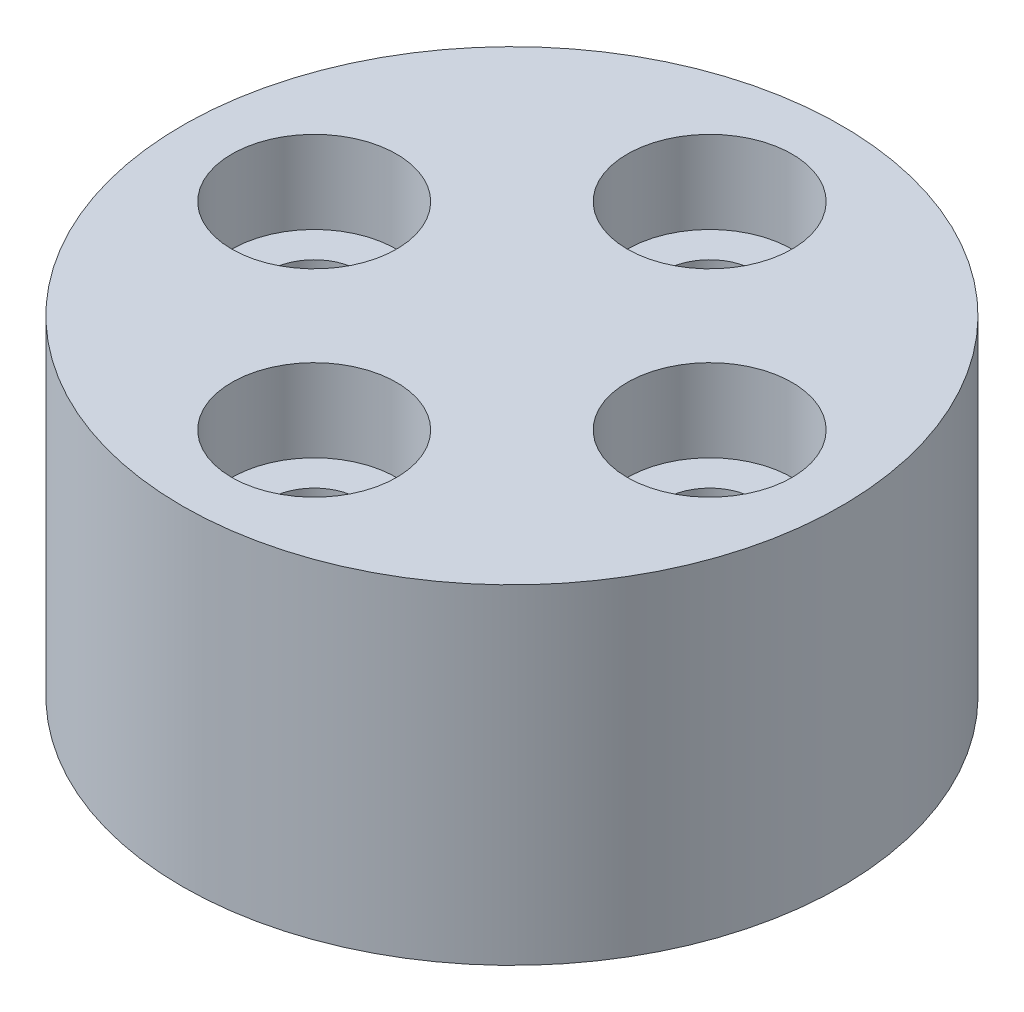
from build123d import *

# Parameters (mm, degrees)
SKETCH1_R                               = 20
BOSS_EXTRUDE1_DEPTH                     = 20
CBORE_FOR_M5_HEX_HEAD_BOLT5_D           = 5.5
CBORE_FOR_M5_HEX_HEAD_BOLT5_CBORE_D     = 10
CBORE_FOR_M5_HEX_HEAD_BOLT5_CBORE_DEPTH = 5


with BuildPart() as part:
    # Sketch1 → Boss-Extrude1 (new body)
    with BuildSketch(Plane(origin=(0, 0, 0), x_dir=(1, 0, 0), z_dir=(0, 1, 0))):
        Circle(SKETCH1_R)
    extrude(amount=BOSS_EXTRUDE1_DEPTH)

    # CBORE for M5 Hex Head Bolt5 (through all)
    with Locations(Plane(origin=(0, 20, -12), x_dir=(0, 0, 1), z_dir=(0, 1, 0))):
        with Locations((0, 0), (12, 12), (24, 0), (12, -12)):
            CounterBoreHole(CBORE_FOR_M5_HEX_HEAD_BOLT5_D / 2, CBORE_FOR_M5_HEX_HEAD_BOLT5_CBORE_D / 2, CBORE_FOR_M5_HEX_HEAD_BOLT5_CBORE_DEPTH)


solid = part.part
